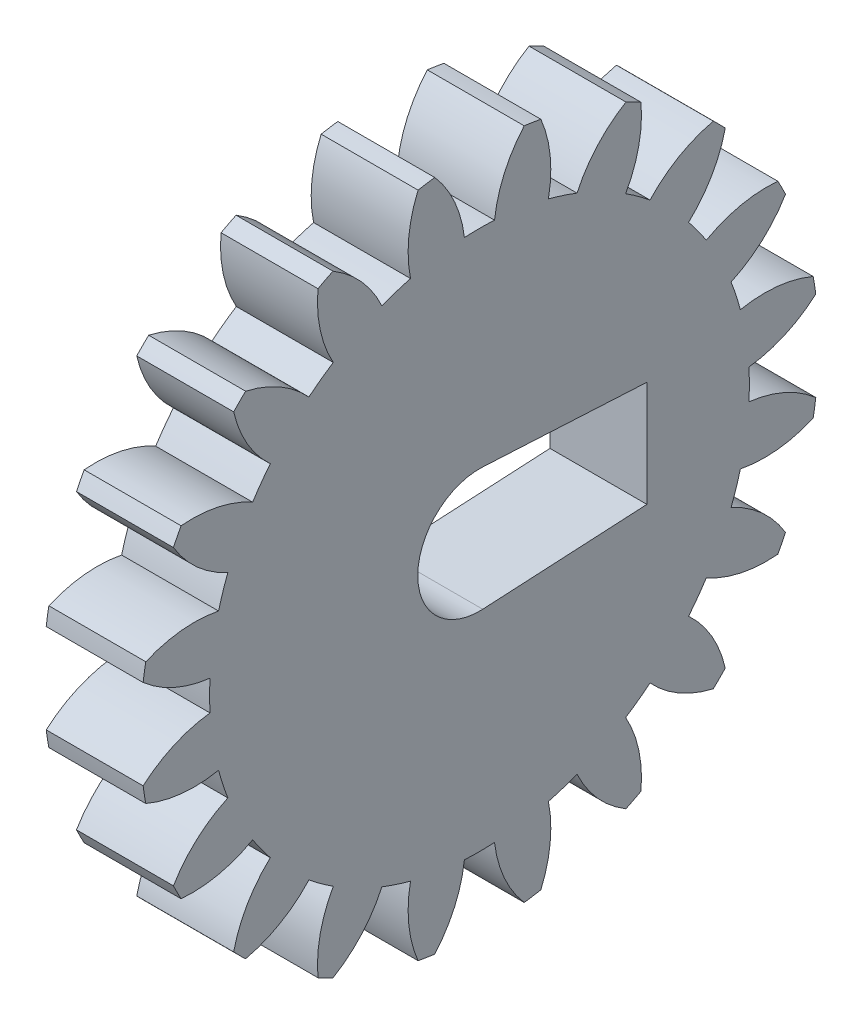
from build123d import *

# Parameters (mm, degrees)
BASPROSKE_W         = 10
BASPROSKE_H         = 19.25
TOOTHCUT_DEPTH      = 30.002155092
TEETHCUTS_COUNT     = 20
TEETHCUTS_ANGLE     = 342
BORSKE_R            = 0.4
BORE_DEPTH          = 50.0000508
SKETCH1_R           = 2.5
CUT_EXTRUDE1_DEPTH  = 29.779222719
CUT_EXTRUDE_1_DEPTH = 5.5
SKETCH_4_R          = 25
CUT_EXTRUDE_2_DEPTH = 4.5


with BuildPart() as part:
    # BasProSke → Base-Revolve (revolve)
    with BuildSketch(Plane(origin=(0, 0, 0), x_dir=(1, 0, 0), z_dir=(0, 1, 0)), mode=Mode.PRIVATE) as base_revolve_sk:
        with Locations((5, 9.625)):
            Rectangle(BASPROSKE_W, BASPROSKE_H)
    revolve(base_revolve_sk.sketch.rotate(Axis((-10, 0, 0), (1, 0, 0)), 180), axis=Axis((-10, 0, 0), (1, 0, 0)))

    # TooCutSke → ToothCut (cut, through all)
    with BuildSketch(Plane(origin=(0, 0, 0), x_dir=(0, 0, -1), z_dir=(1, 0, 0))):
        with BuildLine():
            ThreePointArc((0.85426341, 15.287650777), (0, 15.3115), (-0.85426341, 15.287650777))
            ThreePointArc((-0.85426341, 15.287650777), (-1.414533498, 17.326428412), (-2.557997552, 19.104912815))
            ThreePointArc((-2.557997552, 19.104912815), (0, 19.2754), (2.557997552, 19.104912815))
            ThreePointArc((2.557997552, 19.104912815), (1.414533498, 17.326428412), (0.85426341, 15.287650777))
        make_face()
    toothcut = extrude(amount=TOOTHCUT_DEPTH, mode=Mode.SUBTRACT)

    # TeethCuts: ToothCut ×20 about axis
    teethcuts_axis = Axis((-10, 0, 0), (1, 0, 0))
    for i in range(1, TEETHCUTS_COUNT):
        add(toothcut.rotate(teethcuts_axis, i * TEETHCUTS_ANGLE / (TEETHCUTS_COUNT - 1)), mode=Mode.SUBTRACT)

    # BorSke → Bore (cut, symmetric)
    with BuildSketch(Plane(origin=(0, 0, 0), x_dir=(0, 0, -1), z_dir=(1, 0, 0))):
        with Locations(Location((0, 0, 0), (0, 0, 180))):
            Circle(BORSKE_R)
    extrude(amount=BORE_DEPTH, both=True, mode=Mode.SUBTRACT)

    # Sketch1 → Cut-Extrude1 (cut, through all)
    with BuildSketch(Plane(origin=(10, 0, 0), x_dir=(0, 0, -1), z_dir=(1, 0, 0))):
        Circle(SKETCH1_R)
    extrude(amount=-CUT_EXTRUDE1_DEPTH, mode=Mode.SUBTRACT)

    # 草图2 → 切除-拉伸1 (cut)
    with BuildSketch(Plane(origin=(10, 0, 0), x_dir=(0, 0, -1), z_dir=(1, 0, 0))):
        with BuildLine():
            ThreePointArc((0.185768463, 3.495066534), (-2.408299232, 2.539703685), (-3.5, 0))
            Line((-3.5, 0), (9.5, 0))
            Line((9.5, 0), (9.5, 3))
            Line((9.5, 3), (0.185768463, 3.495066534))
        make_face()
        with BuildLine():
            Line((9.5, 0), (-3.5, 0))
            ThreePointArc((-3.5, 0), (-2.408299232, -2.539703685), (0.185768463, -3.495066534))
            Line((0.185768463, -3.495066534), (9.5, -3))
            Line((9.5, -3), (9.5, 0))
        make_face()
    extrude(amount=-CUT_EXTRUDE_1_DEPTH, mode=Mode.SUBTRACT)

    # 草图4 → 切除-拉伸2 (cut)
    with BuildSketch(Plane.ZY):
        Circle(SKETCH_4_R)
    extrude(amount=-CUT_EXTRUDE_2_DEPTH, mode=Mode.SUBTRACT)


solid = part.part
